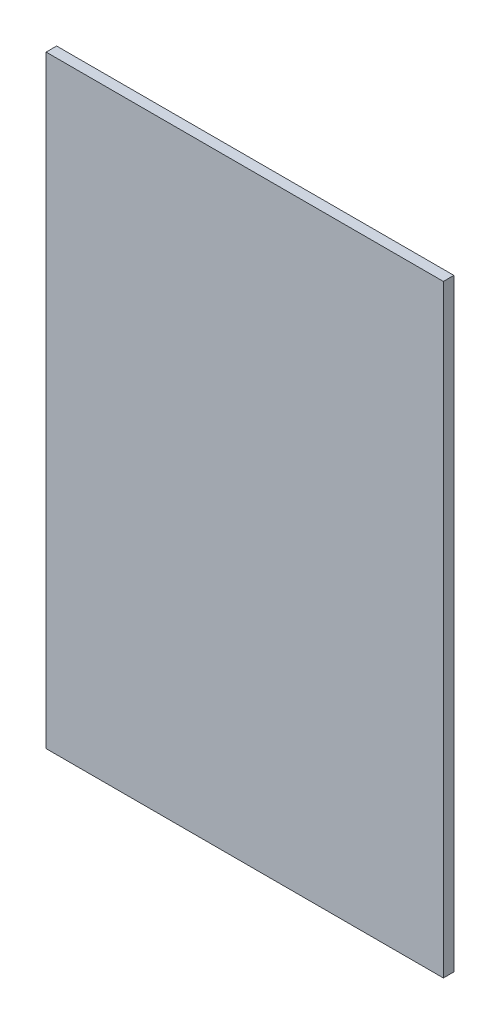
from build123d import *

# Parameters (mm, degrees)
ESQUISSE1_W             = 1134
ESQUISSE1_H             = 1722
BOSS_EXTRU_1_DEPTH      = 30
ESQUISSE6_W             = 1038.990735542
ESQUISSE6_H             = 1577.726672488
ENL_V_MAT_EXTRU_1_DEPTH = 27
ESQUISSE7_W             = 1127.272234852
ESQUISSE7_H             = 1708.57841833
ENL_V_MAT_EXTRU_2_DEPTH = 24
ENL_V_MAT_EXTRU_3_DEPTH = 10


with BuildPart() as part:
    # Esquisse1 → Boss.-Extru.1 (new body)
    with BuildSketch(Plane.XY):
        Rectangle(ESQUISSE1_W, ESQUISSE1_H)
    extrude(amount=BOSS_EXTRU_1_DEPTH)

    # Esquisse6 → Enlèv. mat.-Extru.1 (cut)
    with BuildSketch(Plane(origin=(0, 0, 0), x_dir=(-1, 0, 0), z_dir=(0, 0, -1))):
        Rectangle(ESQUISSE6_W, ESQUISSE6_H)
    extrude(amount=-ENL_V_MAT_EXTRU_1_DEPTH, mode=Mode.SUBTRACT)

    # Esquisse7 → Enlèv. mat.-Extru.2 (cut)
    with BuildSketch(Plane(origin=(0, 0, 27), x_dir=(-1, 0, 0), z_dir=(0, 0, -1))):
        Rectangle(ESQUISSE7_W, ESQUISSE7_H)
    extrude(amount=ENL_V_MAT_EXTRU_2_DEPTH, mode=Mode.SUBTRACT)

    # trous fixation → Enlèv. mat.-Extru.3 (cut)
    with BuildSketch(Plane(origin=(0, 0, 0), x_dir=(-1, 0, 0), z_dir=(0, 0, -1))):
        with BuildLine():
            Line((-543.5, 693), (-542.5, 693))
            ThreePointArc((-542.5, 693), (-539.671572875, 694.171572875), (-538.5, 697))
            Line((-538.5, 697), (-538.5, 703))
            ThreePointArc((-538.5, 703), (-539.671572875, 705.828427125), (-542.5, 707))
            Line((-542.5, 707), (-543.5, 707))
            ThreePointArc((-543.5, 707), (-546.328427125, 705.828427125), (-547.5, 703))
            Line((-547.5, 703), (-547.5, 697))
            ThreePointArc((-547.5, 697), (-546.328427125, 694.171572875), (-543.5, 693))
        make_face()
        with BuildLine():
            Line((-543.5, 423), (-542.5, 423))
            ThreePointArc((-542.5, 423), (-539.671572875, 424.171572875), (-538.5, 427))
            Line((-538.5, 427), (-538.5, 433))
            ThreePointArc((-538.5, 433), (-539.671572875, 435.828427125), (-542.5, 437))
            Line((-542.5, 437), (-543.5, 437))
            ThreePointArc((-543.5, 437), (-546.328427125, 435.828427125), (-547.5, 433))
            Line((-547.5, 433), (-547.5, 427))
            ThreePointArc((-547.5, 427), (-546.328427125, 424.171572875), (-543.5, 423))
        make_face()
        with BuildLine():
            Line((-543.5, -437), (-542.5, -437))
            ThreePointArc((-542.5, -437), (-539.671572875, -435.828427125), (-538.5, -433))
            Line((-538.5, -433), (-538.5, -427))
            ThreePointArc((-538.5, -427), (-539.671572875, -424.171572875), (-542.5, -423))
            Line((-542.5, -423), (-543.5, -423))
            ThreePointArc((-543.5, -423), (-546.328427125, -424.171572875), (-547.5, -427))
            Line((-547.5, -427), (-547.5, -433))
            ThreePointArc((-547.5, -433), (-546.328427125, -435.828427125), (-543.5, -437))
        make_face()
        with BuildLine():
            Line((-543.5, -707), (-542.5, -707))
            ThreePointArc((-542.5, -707), (-539.671572875, -705.828427125), (-538.5, -703))
            Line((-538.5, -703), (-538.5, -697))
            ThreePointArc((-538.5, -697), (-539.671572875, -694.171572875), (-542.5, -693))
            Line((-542.5, -693), (-543.5, -693))
            ThreePointArc((-543.5, -693), (-546.328427125, -694.171572875), (-547.5, -697))
            Line((-547.5, -697), (-547.5, -703))
            ThreePointArc((-547.5, -703), (-546.328427125, -705.828427125), (-543.5, -707))
        make_face()
        with BuildLine():
            Line((538.5, -703), (538.5, -697))
            ThreePointArc((538.5, -697), (539.671572875, -694.171572875), (542.5, -693))
            Line((542.5, -693), (543.5, -693))
            ThreePointArc((543.5, -693), (546.328427125, -694.171572875), (547.5, -697))
            Line((547.5, -697), (547.5, -703))
            ThreePointArc((547.5, -703), (546.328427125, -705.828427125), (543.5, -707))
            Line((543.5, -707), (542.5, -707))
            ThreePointArc((542.5, -707), (539.671572875, -705.828427125), (538.5, -703))
        make_face()
        with BuildLine():
            Line((538.5, -433), (538.5, -427))
            ThreePointArc((538.5, -427), (539.671572875, -424.171572875), (542.5, -423))
            Line((542.5, -423), (543.5, -423))
            ThreePointArc((543.5, -423), (546.328427125, -424.171572875), (547.5, -427))
            Line((547.5, -427), (547.5, -433))
            ThreePointArc((547.5, -433), (546.328427125, -435.828427125), (543.5, -437))
            Line((543.5, -437), (542.5, -437))
            ThreePointArc((542.5, -437), (539.671572875, -435.828427125), (538.5, -433))
        make_face()
        with BuildLine():
            Line((538.5, 427), (538.5, 433))
            ThreePointArc((538.5, 433), (539.671572875, 435.828427125), (542.5, 437))
            Line((542.5, 437), (543.5, 437))
            ThreePointArc((543.5, 437), (546.328427125, 435.828427125), (547.5, 433))
            Line((547.5, 433), (547.5, 427))
            ThreePointArc((547.5, 427), (546.328427125, 424.171572875), (543.5, 423))
            Line((543.5, 423), (542.5, 423))
            ThreePointArc((542.5, 423), (539.671572875, 424.171572875), (538.5, 427))
        make_face()
        with BuildLine():
            Line((538.5, 697), (538.5, 703))
            ThreePointArc((538.5, 703), (539.671572875, 705.828427125), (542.5, 707))
            Line((542.5, 707), (543.5, 707))
            ThreePointArc((543.5, 707), (546.328427125, 705.828427125), (547.5, 703))
            Line((547.5, 703), (547.5, 697))
            ThreePointArc((547.5, 697), (546.328427125, 694.171572875), (543.5, 693))
            Line((543.5, 693), (542.5, 693))
            ThreePointArc((542.5, 693), (539.671572875, 694.171572875), (538.5, 697))
        make_face()
    extrude(amount=-ENL_V_MAT_EXTRU_3_DEPTH, mode=Mode.SUBTRACT)


solid = part.part
